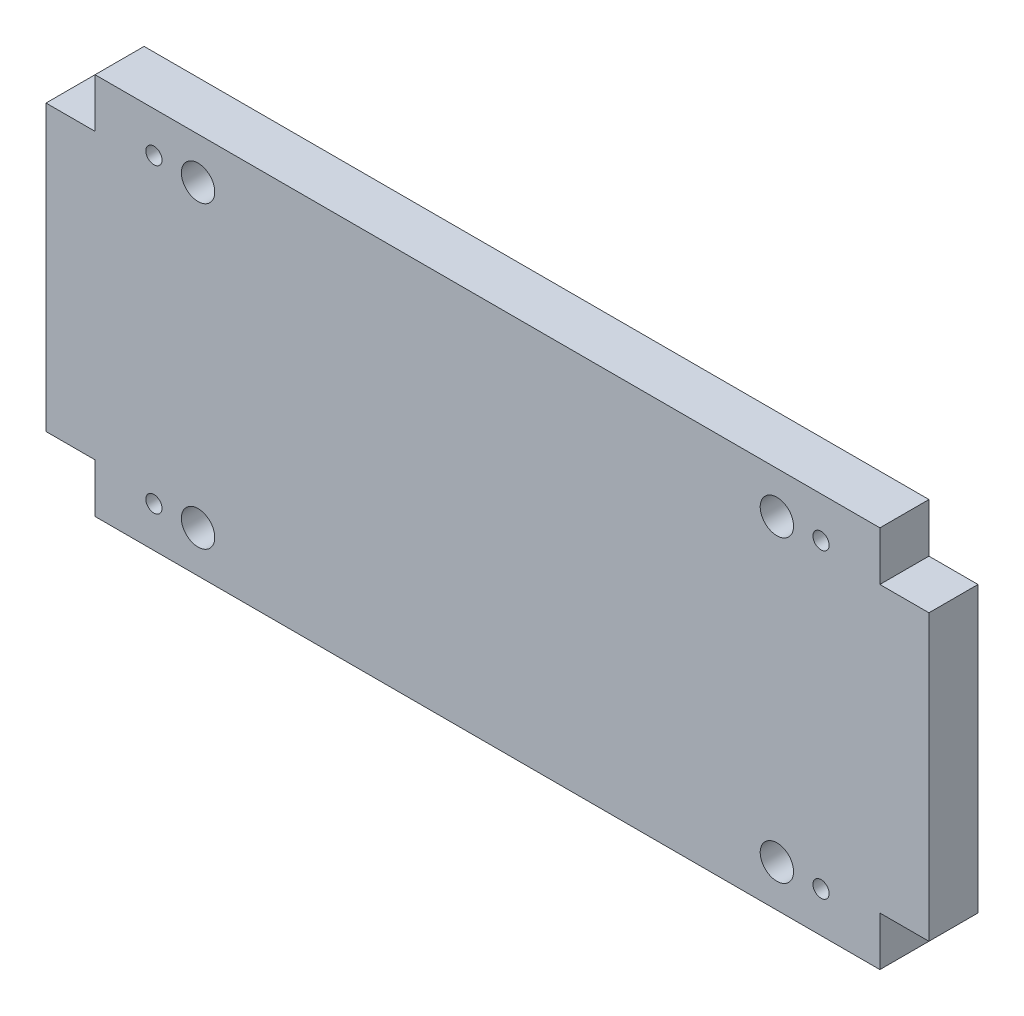
from build123d import *

# Parameters (mm, degrees)
BOSS_EXTRUDE1_DEPTH = 10
M4_TAPPED_HOLE1_D   = 3.3
M8_TAPPED_HOLE1_D   = 6.8


with BuildPart() as part:
    # Sketch1 → Boss-Extrude1 (new body)
    with BuildSketch(Plane.XY):
        Polygon((-80, 39), (80, 39), (80, 29), (90, 29), (90, -29), (80, -29), (80, -39), (-80, -39), (-80, -29), (-90, -29), (-90, 29), (-80, 29), align=None)
    extrude(amount=BOSS_EXTRUDE1_DEPTH)

    # M4 Tapped Hole1 (through all)
    with Locations(Plane.XY.offset(10)):
        with Locations((-68, 30.75), (-68, -30.75), (68, -30.75), (68, 30.75)):
            Hole(M4_TAPPED_HOLE1_D / 2)

    # M8 Tapped Hole1 (through all)
    with Locations(Plane.XY.offset(10)):
        with Locations((-59, 30.5), (-59, -30.5), (59, -30.5), (59, 30.5)):
            Hole(M8_TAPPED_HOLE1_D / 2)


solid = part.part
